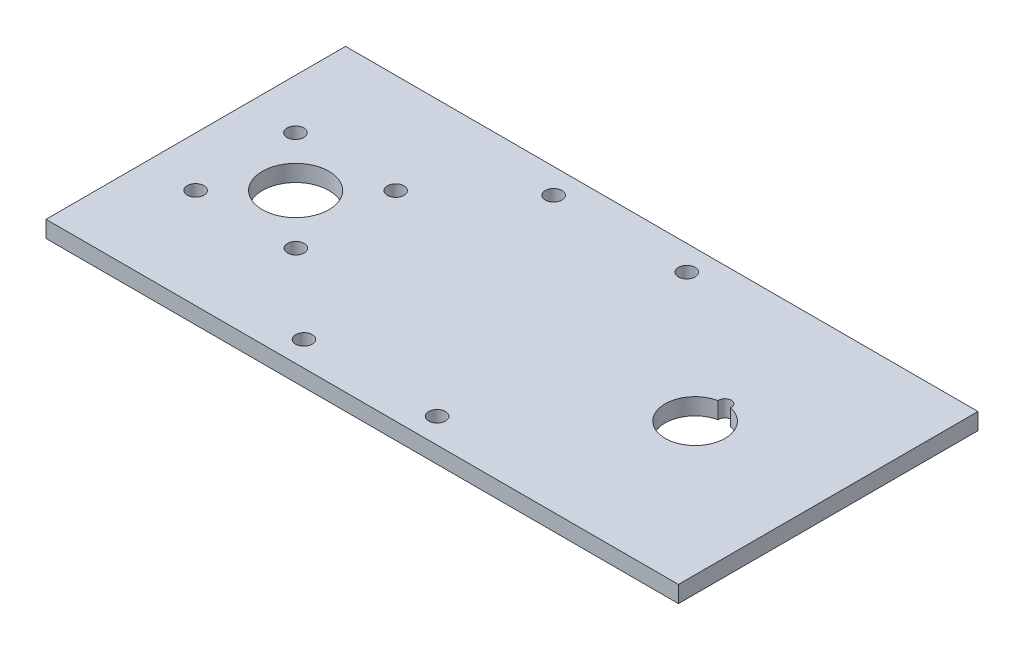
from build123d import *

# Parameters (mm, degrees)
SKETCH1_W           = 241.3
SKETCH1_H           = 114.3
SKETCH1_R           = 12.7
SKETCH1_R_2         = 3.175
BOSS_EXTRUDE1_DEPTH = 6.35


with BuildPart() as part:
    # Sketch1 → Boss-Extrude1 (new body)
    with BuildSketch(Plane(origin=(0, 0, 0), x_dir=(1, 0, 0), z_dir=(0, 1, 0))):
        with Locations((120.65, 57.15)):
            Rectangle(SKETCH1_W, SKETCH1_H)
        with Locations((38.1, 57.15)):
            Circle(SKETCH1_R, mode=Mode.SUBTRACT)
        with Locations((88.9, 104.775)):
            Circle(SKETCH1_R_2, mode=Mode.SUBTRACT)
        with Locations((139.7, 104.775)):
            Circle(SKETCH1_R_2, mode=Mode.SUBTRACT)
        with Locations((139.7, 9.525)):
            Circle(SKETCH1_R_2, mode=Mode.SUBTRACT)
        with Locations((88.9, 9.525)):
            Circle(SKETCH1_R_2, mode=Mode.SUBTRACT)
        with Locations((18.983968606, 76.2)):
            Circle(SKETCH1_R_2, mode=Mode.SUBTRACT)
        with Locations((18.983968606, 38.1)):
            Circle(SKETCH1_R_2, mode=Mode.SUBTRACT)
        with Locations((57.216031394, 38.1)):
            Circle(SKETCH1_R_2, mode=Mode.SUBTRACT)
        with Locations((57.216031394, 76.2)):
            Circle(SKETCH1_R_2, mode=Mode.SUBTRACT)
        with BuildLine():
            ThreePointArc((188.131704345, 68.331953125), (190.5, 45.72), (192.868295655, 68.331953125))
            ThreePointArc((192.868295655, 68.331953125), (190.5, 70.96125), (188.131704345, 68.331953125))
        make_face(mode=Mode.SUBTRACT)
    extrude(amount=BOSS_EXTRUDE1_DEPTH)


solid = part.part
